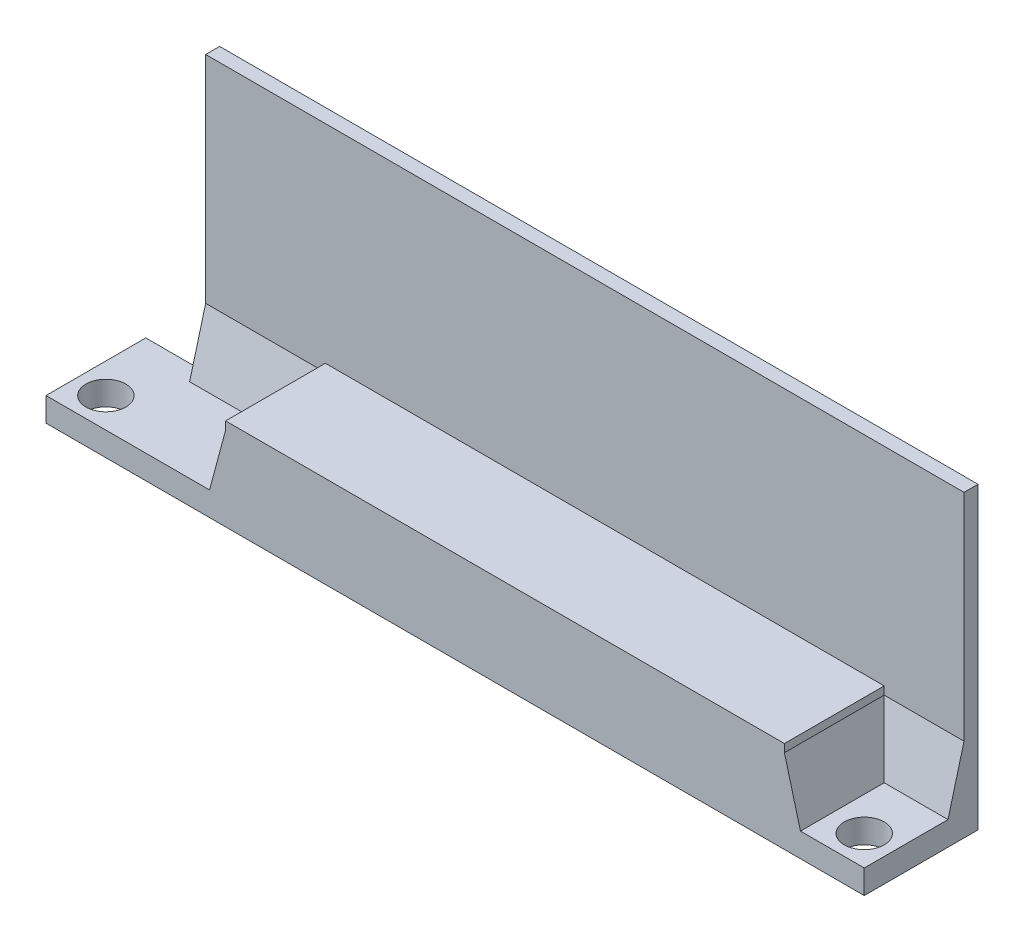
from build123d import *

# Parameters (mm, degrees)
SKETCH1_W             = 41
SKETCH1_H             = 5
SKETCH1_R             = 1
BOSS_EXTRUDE1_DEPTH   = 10
CUT_EXTRUDE1_DEPTH    = 10
SKETCH4_W             = 38
SKETCH4_H             = 15
BOSS_EXTRUDE2_DEPTH   = 0.7
SKETCH3_W             = 26.4
SKETCH3_H             = 3.8
CUT_EXTRUDE2_DEPTH    = 10
CHAMFER1_SIZE         = 3
CHAMFER1_SIZE2        = 0.803847577
CHAMFER1_PART_2_SIZE  = 3
CHAMFER1_PART_2_SIZE2 = 0.803847577
CHAMFER1_PART_3_SIZE  = 3
CHAMFER1_PART_3_SIZE2 = 0.803847577
SKETCH7_W             = 26.4
SKETCH7_H             = 3.8
BOSS_EXTRUDE3_DEPTH   = 0.8


with BuildPart() as part:
    # Sketch1 → Boss-Extrude1 (new body)
    with BuildSketch(Plane(origin=(0, 0, 0), x_dir=(1, 0, 0), z_dir=(0, 1, 0))):
        with Locations((20.5, 2.5)):
            Rectangle(SKETCH1_W, SKETCH1_H)
        with Locations((1.5, 1.5)):
            Circle(SKETCH1_R, mode=Mode.SUBTRACT)
        with Locations((39.5, 1.5)):
            Circle(SKETCH1_R, mode=Mode.SUBTRACT)
    extrude(amount=BOSS_EXTRUDE1_DEPTH)

    # Sketch2 → Cut-Extrude1 (cut)
    with BuildSketch(Plane.XY):
        Polygon((0, 10), (0, 1.2), (9, 1.2), (9, 4.6), (37, 4.6), (37, 1.2), (41, 1.2), (41, 10), align=None)
    extrude(amount=-CUT_EXTRUDE1_DEPTH, mode=Mode.SUBTRACT)

    # Sketch4 → Boss-Extrude2 (add)
    with BuildSketch(Plane(origin=(0, 0, -5), x_dir=(-1, 0, 0), z_dir=(0, 0, -1))):
        with Locations((-22, 7.5)):
            Rectangle(SKETCH4_W, SKETCH4_H)
    extrude(amount=BOSS_EXTRUDE2_DEPTH)

    # Sketch3 → Cut-Extrude2 (cut)
    with BuildSketch(Plane.XY):
        with Locations((23, 1.9)):
            Rectangle(SKETCH3_W, SKETCH3_H)
    extrude(amount=-CUT_EXTRUDE2_DEPTH, mode=Mode.SUBTRACT)

    # Chamfer1
    chamfer1_edges = [part.edges().sort_by_distance(p)[0] for p in [
        (37, 1.2, -2.5),
    ]]
    chamfer1_side = [part.faces().sort_by_distance(p)[0] for p in [
        (37, 2.9, -2.5),
    ]]
    chamfer(chamfer1_edges, length=CHAMFER1_SIZE, length2=CHAMFER1_SIZE2, reference=chamfer1_side[0])

    # Chamfer1 part 2
    chamfer1_part_2_edges = [part.edges().sort_by_distance(p)[0] for p in [
        (9, 1.2, -2.5),
    ]]
    chamfer1_part_2_side = [part.faces().sort_by_distance(p)[0] for p in [
        (9, 2.9, -2.5),
    ]]
    chamfer(chamfer1_part_2_edges, length=CHAMFER1_PART_2_SIZE, length2=CHAMFER1_PART_2_SIZE2, reference=chamfer1_part_2_side[0])

    # Chamfer1 part 3
    chamfer1_part_3_edges = [part.edges().sort_by_distance(p)[0] for p in [
        (39, 1.2, -5),
        (6, 1.2, -5),
    ]]
    chamfer1_part_3_side = [part.faces().sort_by_distance(p)[0] for p in [
        (21.778191985, 9.253401678, -5),
    ]]
    chamfer(chamfer1_part_3_edges, length=CHAMFER1_PART_3_SIZE, length2=CHAMFER1_PART_3_SIZE2, reference=chamfer1_part_3_side[0])

    # Sketch7 → Boss-Extrude3 (add)
    with BuildSketch(Plane.XY):
        with Locations((23, 1.9)):
            Rectangle(SKETCH7_W, SKETCH7_H)
    extrude(amount=-BOSS_EXTRUDE3_DEPTH)


solid = part.part
